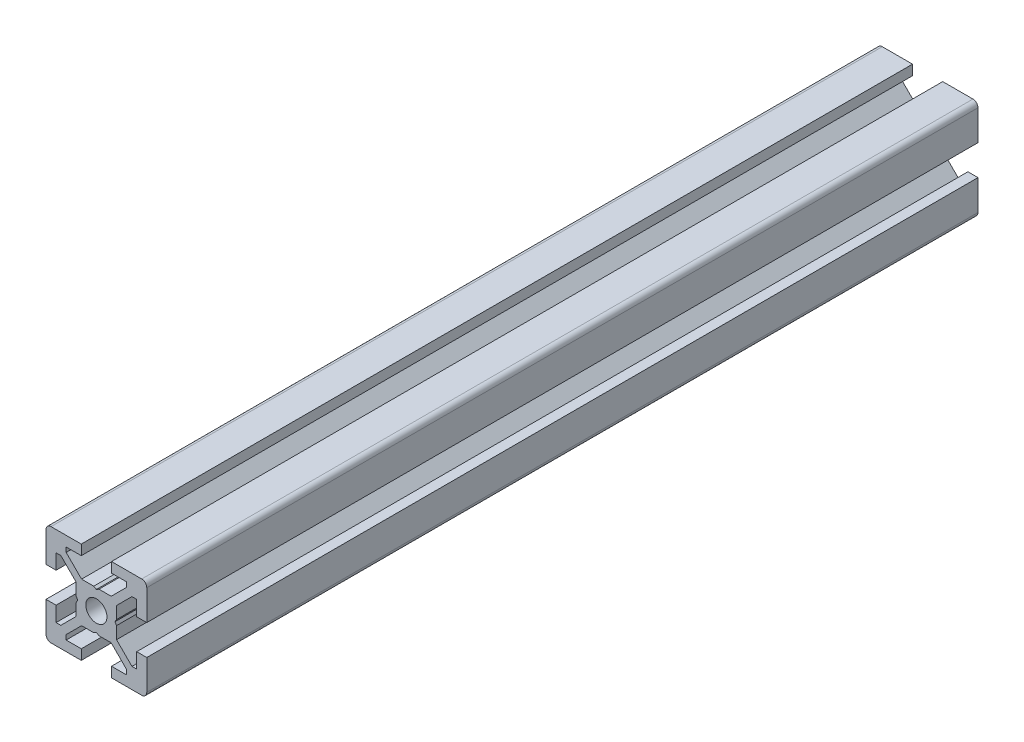
from build123d import *

# Parameters (mm, degrees)
EXTRUDE_1_DEPTH = 165
SKETCH_2_W      = 260
SKETCH_2_H      = 2.1


with BuildPart() as part:
    # ｽｹｯﾁ1 → ﾎﾞｽ - 押し出し1 (new body)
    with BuildSketch(Plane.XY):
        with BuildLine():
            Line((-10, -3), (-10, -9))
            ThreePointArc((-10, -9), (-9.707106781, -9.707106781), (-9, -10))
            Line((-9, -10), (-3, -10))
            Line((-3, -10), (-3, -8))
            Line((-3, -8), (-6, -8))
            Line((-6, -8), (-6, -7.060660172))
            Line((-6, -7.060660172), (-2.939339828, -4))
            Line((-2.939339828, -4), (-0.519615242, -4))
            Line((-0.519615242, -4), (0, -3.7))
            Line((0, -3.7), (0.519615242, -4))
            Line((0.519615242, -4), (2.939339828, -4))
            Line((2.939339828, -4), (6, -7.060660172))
            Line((6, -7.060660172), (6, -8))
            Line((6, -8), (3, -8))
            Line((3, -8), (3, -10))
            Line((3, -10), (9, -10))
            ThreePointArc((9, -10), (9.707106781, -9.707106781), (10, -9))
            Line((10, -9), (10, -3))
            Line((10, -3), (8, -3))
            Line((8, -3), (8, -6))
            Line((8, -6), (7.060660172, -6))
            Line((7.060660172, -6), (4, -2.939339828))
            Line((4, -2.939339828), (4, -0.519615242))
            Line((4, -0.519615242), (3.7, 0))
            Line((3.7, 0), (4, 0.519615242))
            Line((4, 0.519615242), (4, 2.939339828))
            Line((4, 2.939339828), (7.060660172, 6))
            Line((7.060660172, 6), (8, 6))
            Line((8, 6), (8, 3))
            Line((8, 3), (10, 3))
            Line((10, 3), (10, 9))
            ThreePointArc((10, 9), (9.707106781, 9.707106781), (9, 10))
            Line((9, 10), (3, 10))
            Line((3, 10), (3, 8))
            Line((3, 8), (6, 8))
            Line((6, 8), (6, 7.060660172))
            Line((6, 7.060660172), (2.939339828, 4))
            Line((2.939339828, 4), (0.519615242, 4))
            Line((0.519615242, 4), (0, 3.7))
            Line((0, 3.7), (-0.519615242, 4))
            Line((-0.519615242, 4), (-2.939339828, 4))
            Line((-2.939339828, 4), (-6, 7.060660172))
            Line((-6, 7.060660172), (-6, 8))
            Line((-6, 8), (-3, 8))
            Line((-3, 8), (-3, 10))
            Line((-3, 10), (-9, 10))
            ThreePointArc((-9, 10), (-9.707106781, 9.707106781), (-10, 9))
            Line((-10, 9), (-10, 3))
            Line((-10, 3), (-8, 3))
            Line((-8, 3), (-8, 6))
            Line((-8, 6), (-7.060660172, 6))
            Line((-7.060660172, 6), (-4, 2.939339828))
            Line((-4, 2.939339828), (-4, 0.519615242))
            Line((-4, 0.519615242), (-3.7, 0))
            Line((-3.7, 0), (-4, -0.519615242))
            Line((-4, -0.519615242), (-4, -2.939339828))
            Line((-4, -2.939339828), (-7.060660172, -6))
            Line((-7.060660172, -6), (-8, -6))
            Line((-8, -6), (-8, -3))
            Line((-8, -3), (-10, -3))
        make_face()
    extrude(amount=-EXTRUDE_1_DEPTH)

    # ｽｹｯﾁ2 → ｶｯﾄ - 回転1 (revolve, cut)
    with BuildSketch(Plane(origin=(0, 0, 0), x_dir=(0, 0, -1), z_dir=(1, 0, 0))):
        with Locations((130, 1.05)):
            Rectangle(SKETCH_2_W, SKETCH_2_H)
    revolve(axis=Axis((0, 0, -260), (0, 0, 1)), mode=Mode.SUBTRACT)


solid = part.part
